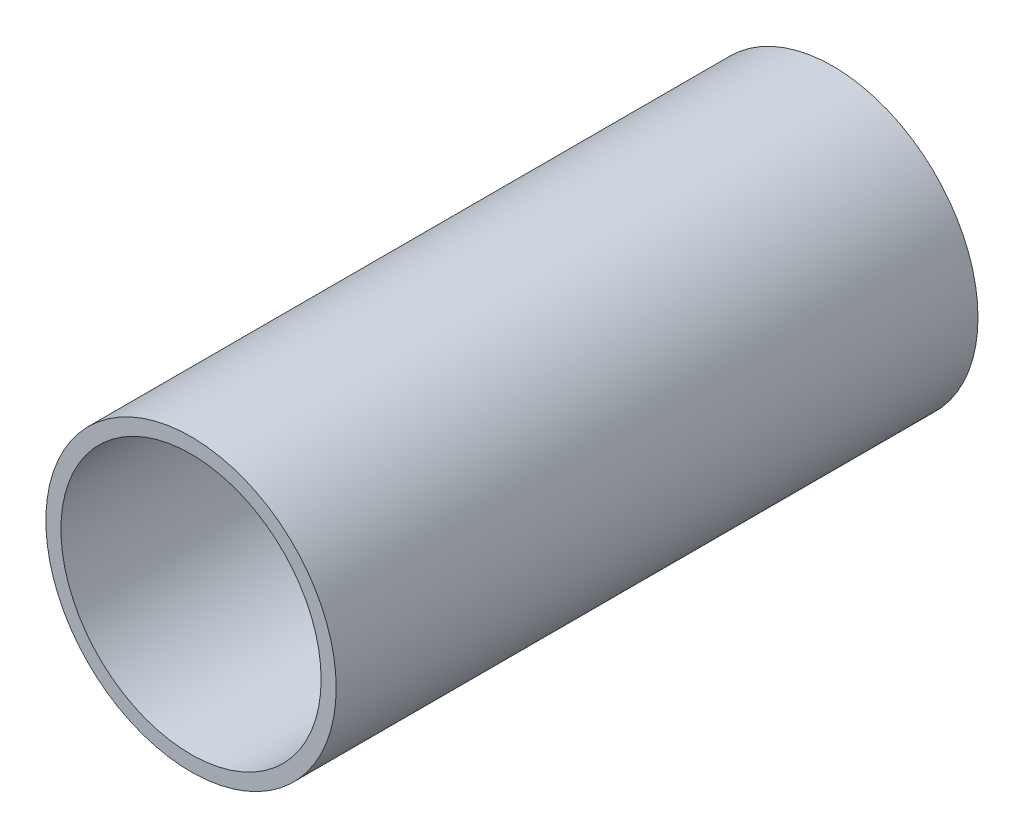
from build123d import *

# Parameters (mm, degrees)
SKETCH1_R           = 4.826
BOSS_EXTRUDE1_DEPTH = 30.988
SKETCH2_R           = 4.325
CUT_EXTRUDE1_DEPTH  = 37
SKETCH3_R           = 4.826
SKETCH3_R_2         = 4.325
CUT_EXTRUDE2_DEPTH  = 9.652
SKETCH5_R           = 4.325
SKETCH5_R_2         = 3.81
BOSS_EXTRUDE3_DEPTH = 0.635


with BuildPart() as part:
    # Sketch1 → Boss-Extrude1 (new body)
    with BuildSketch(Plane.XY):
        Circle(SKETCH1_R)
    extrude(amount=BOSS_EXTRUDE1_DEPTH)

    # Sketch2 → Cut-Extrude1 (cut)
    with BuildSketch(Plane.XY.offset(30.988)):
        Circle(SKETCH2_R)
    extrude(amount=-CUT_EXTRUDE1_DEPTH, mode=Mode.SUBTRACT)

    # Sketch3 → Cut-Extrude2 (cut)
    with BuildSketch(Plane.XY.offset(30.988)):
        Circle(SKETCH3_R)
        Circle(SKETCH3_R_2, mode=Mode.SUBTRACT)
    extrude(amount=-CUT_EXTRUDE2_DEPTH, mode=Mode.SUBTRACT)

    # Sketch5 → Boss-Extrude3 (add)
    with BuildSketch(Plane(origin=(0, 0, 7.874), x_dir=(-1, 0, 0), z_dir=(0, 0, -1))):
        Circle(SKETCH5_R)
        Circle(SKETCH5_R_2, mode=Mode.SUBTRACT)
    extrude(amount=-BOSS_EXTRUDE3_DEPTH)


solid = part.part
